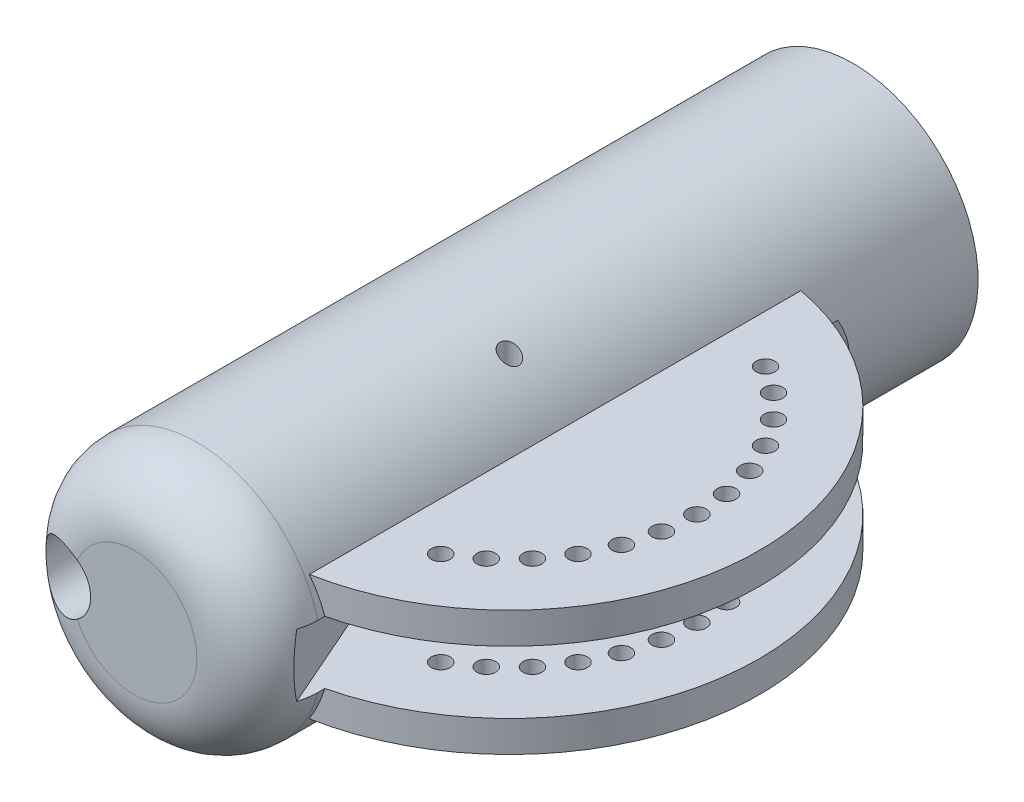
from build123d import *

# Parameters (mm, degrees)
CROQUIS4_R               = 20
SALIENTE_EXTRUIR2_DEPTH  = 100
REDONDEO1_R              = 10
SALIENTE_EXTRUIR6_DEPTH  = 10
CROQUIS6_R               = 6
CROQUIS6_R_2             = 4
SALIENTE_EXTRUIR4_DEPTH  = 15
CROQUIS15_R              = 5
CORTAR_EXTRUIR5_DEPTH    = 91
CORTAR_EXTRUIR2_DEPTH    = 5
CORTAR_EXTRUIR3_DEPTH    = 5
CROQUIS12_R              = 1.5
CORTAR_EXTRUIR4_DEPTH    = 48
CORTAR_EXTRUIR1_START    = -10
CROQUIS6_7_R             = 17
CROQUIS6_7_R_2           = 6
CORTAR_EXTRUIR1_DEPTH    = 10
CROQUIS6_8_R             = 20
CROQUIS6_8_R_2           = 17
SALIENTE_EXTRUIR11_DEPTH = 15


with BuildPart() as part:
    # Croquis4 → Saliente-Extruir2 (new body)
    with BuildSketch(Plane.XY):
        Circle(CROQUIS4_R)
    extrude(amount=-SALIENTE_EXTRUIR2_DEPTH)

    # Redondeo1
    redondeo1_edges = [part.edges().sort_by_distance(p)[0] for p in [
        (-20, 0, 0),
    ]]
    fillet(redondeo1_edges, radius=REDONDEO1_R)

    # Croquis8 → Saliente-Extruir6 (add)
    with BuildSketch(Plane(origin=(0, 0, 0), x_dir=(1, 0, 0), z_dir=(0, 1, 0))):
        with BuildLine():
            Line((10, 48.5), (10, 10))
            ThreePointArc((10, 10), (50, 50), (10, 90))
            Line((10, 90), (10, 51.5))
            ThreePointArc((10, 51.5), (11.5, 50), (10, 48.5))
        make_face()
    saliente_extruir6 = extrude(amount=SALIENTE_EXTRUIR6_DEPTH)

    # Croquis6 → Saliente-Extruir4 (add)
    with BuildSketch(Plane(origin=(0, 0, -100), x_dir=(-1, 0, 0), z_dir=(0, 0, -1))):
        Circle(CROQUIS6_R)
        Circle(CROQUIS6_R_2, mode=Mode.SUBTRACT)
    extrude(amount=SALIENTE_EXTRUIR4_DEPTH)

    # Simetría1: Saliente-Extruir6 across plane
    add(saliente_extruir6.mirror(Plane.ZX))

    # Croquis15 → Cortar-Extruir5 (cut)
    with BuildSketch(Plane.XY):
        with Locations((-12, 0)):
            Circle(CROQUIS15_R)
    extrude(amount=-CORTAR_EXTRUIR5_DEPTH, mode=Mode.SUBTRACT)

    # Croquis10 → Cortar-Extruir2 (cut)
    with BuildSketch(Plane(origin=(0, 0, 0), x_dir=(1, 0, 0), z_dir=(0, 1, 0))):
        with BuildLine():
            Line((17.320508076, 89.324421948), (17.320508076, 10.675578052))
            ThreePointArc((17.320508076, 10.675578052), (50, 50), (17.320508076, 89.324421948))
        make_face()
    cortar_extruir2 = extrude(amount=-CORTAR_EXTRUIR2_DEPTH, mode=Mode.SUBTRACT)

    # Simetría2: Cortar-Extruir2 across plane
    add(cortar_extruir2.mirror(Plane.ZX), mode=Mode.SUBTRACT)

    # Croquis11 → Cortar-Extruir3 (cut)
    with BuildSketch(Plane(origin=(0, 0, 0), x_dir=(1, 0, 0), z_dir=(0, 1, 0))):
        with BuildLine():
            Line((17.320508076, 89.324421948), (2.068713666, 54.962615638))
            ThreePointArc((2.068713666, 54.962615638), (1.051417021, 50.183670554), (2.052033583, 45.401205178))
            Line((2.052033583, 45.401205178), (17.320508076, 10.675578052))
            Line((17.320508076, 10.675578052), (20, 4.581515578))
            Line((20, 4.581515578), (20, 94.364916731))
            Line((20, 94.364916731), (17.320508076, 89.324421948))
        make_face()
    cortar_extruir3 = extrude(amount=-CORTAR_EXTRUIR3_DEPTH, mode=Mode.SUBTRACT)

    # Simetría3: Cortar-Extruir3 across plane
    add(cortar_extruir3.mirror(Plane.ZX), mode=Mode.SUBTRACT)

    # Croquis12 → Cortar-Extruir4 (cut)
    with BuildSketch(Plane(origin=(0, 0, 0), x_dir=(1, 0, 0), z_dir=(0, 1, 0))):
        with Locations((10, 50)):
            Circle(CROQUIS12_R)
        with Locations((40, 50)):
            Circle(CROQUIS12_R)
        with Locations((39.54423259, 55.20944533)):
            Circle(CROQUIS12_R)
        with Locations((38.190778624, 60.2606043)):
            Circle(CROQUIS12_R)
        with Locations((35.980762114, 65)):
            Circle(CROQUIS12_R)
        with Locations((32.981333294, 69.283628291)):
            Circle(CROQUIS12_R)
        with Locations((29.283628291, 72.981333294)):
            Circle(CROQUIS12_R)
        with Locations((25, 75.980762114)):
            Circle(CROQUIS12_R)
        with Locations((39.54423259, 44.79055467)):
            Circle(CROQUIS12_R)
        with Locations((38.190778624, 39.7393957)):
            Circle(CROQUIS12_R)
        with Locations((35.980762114, 35)):
            Circle(CROQUIS12_R)
        with Locations((32.981333294, 30.716371709)):
            Circle(CROQUIS12_R)
        with Locations((29.283628291, 27.018666706)):
            Circle(CROQUIS12_R)
        with Locations((25, 24.019237886)):
            Circle(CROQUIS12_R)
    cortar_extruir4 = extrude(amount=-CORTAR_EXTRUIR4_DEPTH, mode=Mode.SUBTRACT)

    # Croquis6_7 → Cortar-Extruir1 (cut)
    with BuildSketch(Plane(origin=(0, 0, -100), x_dir=(-1, 0, 0), z_dir=(0, 0, -1)).offset(CORTAR_EXTRUIR1_START)):
        Circle(CROQUIS6_7_R)
        Circle(CROQUIS6_7_R_2, mode=Mode.SUBTRACT)
    extrude(amount=CORTAR_EXTRUIR1_DEPTH, mode=Mode.SUBTRACT)

    # Simetría4: Cortar-Extruir4 across plane
    add(cortar_extruir4.mirror(Plane.ZX), mode=Mode.SUBTRACT)

    # Croquis6_8 → Saliente-Extruir11 (add)
    with BuildSketch(Plane(origin=(0, 0, -100), x_dir=(-1, 0, 0), z_dir=(0, 0, -1))):
        Circle(CROQUIS6_8_R)
        Circle(CROQUIS6_8_R_2, mode=Mode.SUBTRACT)
    extrude(amount=SALIENTE_EXTRUIR11_DEPTH)


solid = part.part
